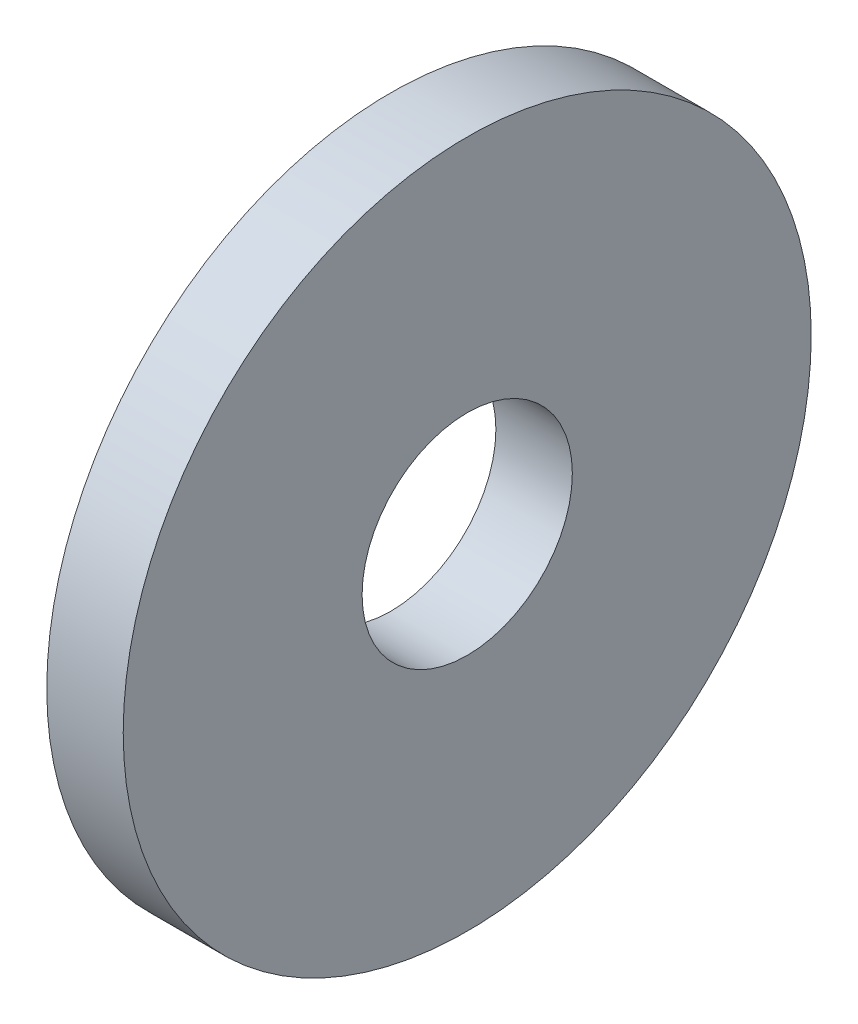
from build123d import *

# Parameters (mm, degrees)
SKETCH1_W = 2
SKETCH1_H = 6.25


with BuildPart() as part:
    # Sketch1 → Base-Revolve (revolve)
    with BuildSketch(Plane.XY):
        with Locations((-1, 5.875)):
            Rectangle(SKETCH1_W, SKETCH1_H)
    revolve(axis=Axis((-34.925, 0, 0), (1, 0, 0)))


solid = part.part
